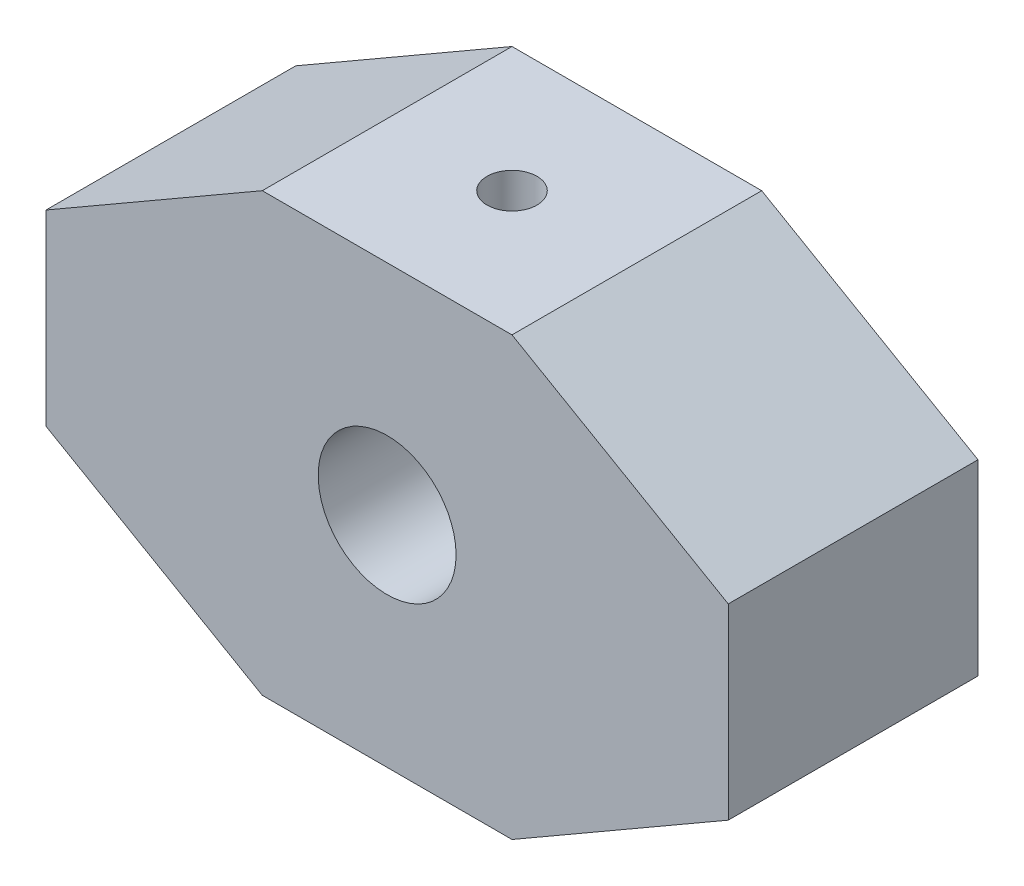
from build123d import *

# Parameters (mm, degrees)
BOSS_EXTRU_1_DEPTH      = 2
ESQUISSE2_R             = 0.552184806
ENL_V_MAT_EXTRU_1_DEPTH = 2
ESQUISSE3_R             = 0.2
ENL_V_MAT_EXTRU_2_DEPTH = 2


with BuildPart() as part:
    # Esquisse1 → Boss.-Extru.1 (new body)
    with BuildSketch(Plane.XY):
        Polygon((-0.363611689, 1.798165138), (-2.095662496, 0.798165138), (-2.095662496, -0.701834862), (-0.363611689, -1.701834862), (1.636388311, -1.701834862), (3.368439119, -0.701834862), (3.368439119, 0.798165138), (1.636388311, 1.798165138), align=None)
    extrude(amount=BOSS_EXTRU_1_DEPTH)

    # Esquisse2 → Enlèv. mat.-Extru.1 (cut)
    with BuildSketch(Plane.XY.offset(2)):
        with Locations((0.636338311, 0.048155138)):
            Circle(ESQUISSE2_R)
    extrude(amount=-ENL_V_MAT_EXTRU_1_DEPTH, mode=Mode.SUBTRACT)

    # Esquisse3 → Enlèv. mat.-Extru.2 (cut)
    with BuildSketch(Plane(origin=(0, 1.798165138, 0), x_dir=(1, 0, 0), z_dir=(0, 1, 0))):
        with Locations((0.636398311, -0.99999)):
            Circle(ESQUISSE3_R)
    extrude(amount=-ENL_V_MAT_EXTRU_2_DEPTH, mode=Mode.SUBTRACT)


solid = part.part
